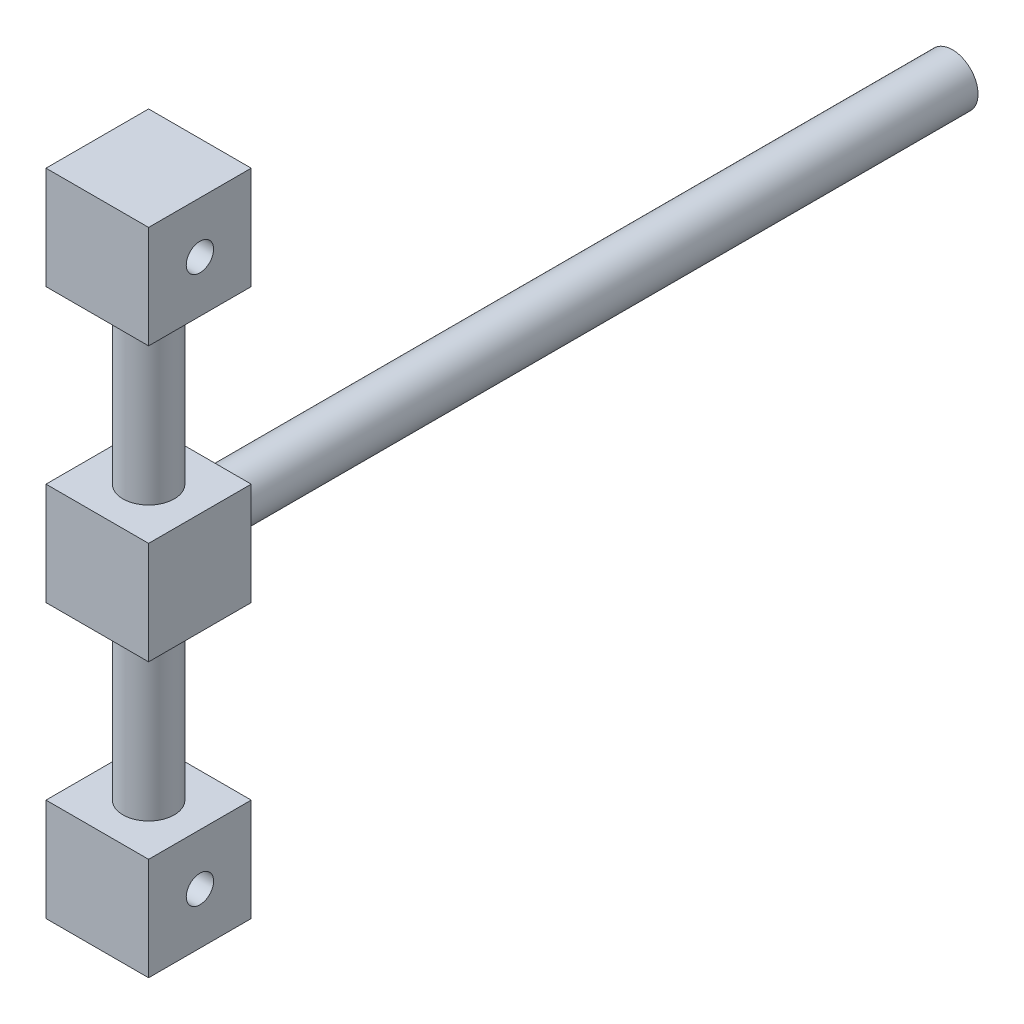
from build123d import *

# Parameters (mm, degrees)
SKETCH_1_W          = 30
SKETCH_1_H          = 30
EXTRUDE_1_DEPTH     = 30
SKETCH_2_R          = 7.5
EXTRUDE_2_DEPTH     = 220
SKETCH_3_R          = 7.5
EXTRUDE_3_DEPTH     = 50
SKETCH_4_W          = 30
SKETCH_4_H          = 30
EXTRUDE_4_DEPTH     = 30
SKETCH_5_R          = 4
CUT_EXTRUDE_1_DEPTH = 31


with BuildPart() as part:
    # 草图1 → 凸台-拉伸1 (new body)
    with BuildSketch(Plane.XY):
        Rectangle(SKETCH_1_W, SKETCH_1_H)
    extrude(amount=EXTRUDE_1_DEPTH)

    # 草图2 → 凸台-拉伸2 (add)
    with BuildSketch(Plane(origin=(0, 0, 0), x_dir=(-1, 0, 0), z_dir=(0, 0, -1))):
        Circle(SKETCH_2_R)
    extrude(amount=EXTRUDE_2_DEPTH)

    # 草图3 → 凸台-拉伸3 (add)
    with BuildSketch(Plane.XZ.offset(15)):
        with Locations((0, 15)):
            Circle(SKETCH_3_R)
    extrude_3 = extrude(amount=EXTRUDE_3_DEPTH)

    # 草图4 → 凸台-拉伸4 (add)
    with BuildSketch(Plane.XZ.offset(65)):
        with Locations((0, 15)):
            Rectangle(SKETCH_4_W, SKETCH_4_H)
    extrude_4 = extrude(amount=EXTRUDE_4_DEPTH)

    # 草图5 → 切除-拉伸1 (cut, through all)
    with BuildSketch(Plane.ZY.offset(15)):
        with Locations((15, -80)):
            Circle(SKETCH_5_R)
    cut_extrude_1 = extrude(amount=-CUT_EXTRUDE_1_DEPTH, mode=Mode.SUBTRACT)

    # 镜向1: 凸台-拉伸3, 凸台-拉伸4, 切除-拉伸1 across plane
    add(extrude_3.mirror(Plane.ZX))
    add(extrude_4.mirror(Plane.ZX))
    add(cut_extrude_1.mirror(Plane.ZX), mode=Mode.SUBTRACT)


solid = part.part
